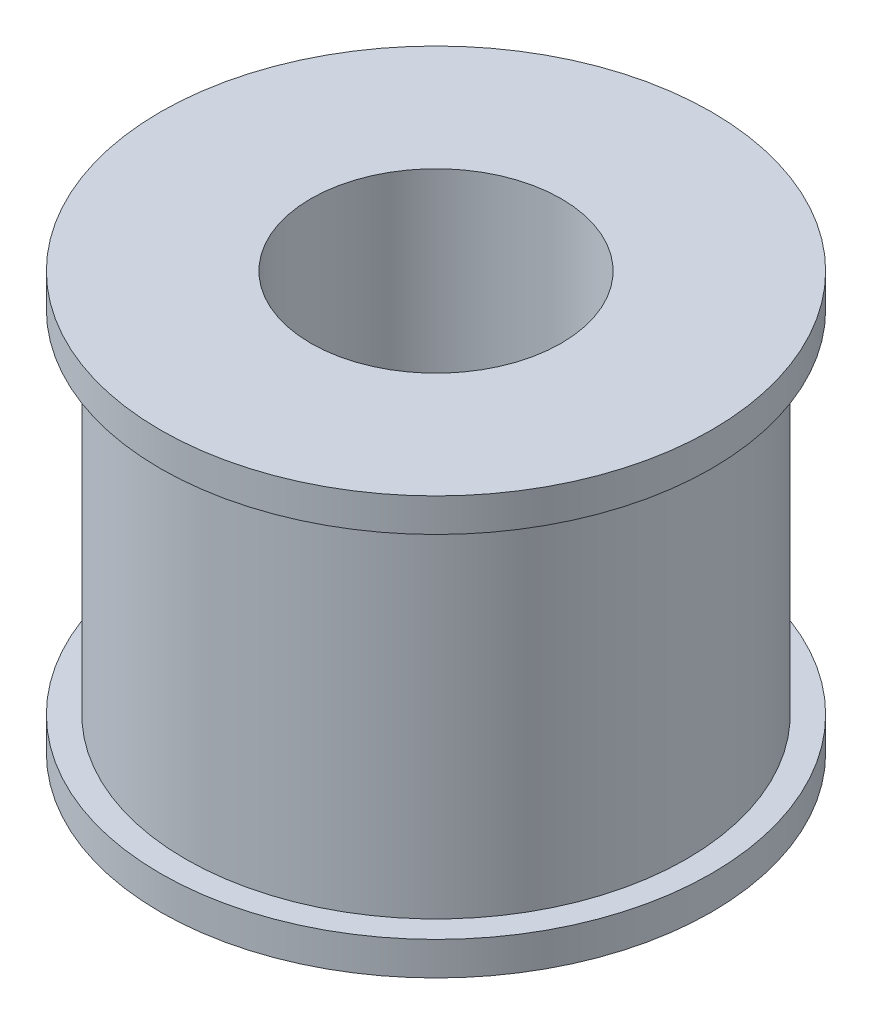
from build123d import *

# Parameters (mm, degrees)
CROQUIS1_R              = 15
CROQUIS1_R_2            = 3
SALIENTE_EXTRUIR1_DEPTH = 25
CROQUIS2_R              = 16.5
CROQUIS2_R_2            = 3
SALIENTE_EXTRUIR2_DEPTH = 2
CROQUIS3_R              = 16.5
CROQUIS3_R_2            = 3
SALIENTE_EXTRUIR3_DEPTH = 2
CORTAR_EXTRUIR1_REACH   = 18.5
CROQUIS4_R              = 1.625
CROQUIS5_R              = 7.5
CORTAR_EXTRUIR2_DEPTH   = 16


with BuildPart() as part:
    # Croquis1 → Saliente-Extruir1 (new body)
    with BuildSketch(Plane(origin=(0, 0, 0), x_dir=(1, 0, 0), z_dir=(0, 1, 0))):
        Circle(CROQUIS1_R)
        Circle(CROQUIS1_R_2, mode=Mode.SUBTRACT)
    extrude(amount=SALIENTE_EXTRUIR1_DEPTH)

    # Croquis2 → Saliente-Extruir2 (add)
    with BuildSketch(Plane.XZ):
        Circle(CROQUIS2_R)
        Circle(CROQUIS2_R_2, mode=Mode.SUBTRACT)
    extrude(amount=-SALIENTE_EXTRUIR2_DEPTH)

    # Croquis3 → Saliente-Extruir3 (add)
    with BuildSketch(Plane(origin=(0, 25, 0), x_dir=(1, 0, 0), z_dir=(0, 1, 0))):
        Circle(CROQUIS3_R)
        Circle(CROQUIS3_R_2, mode=Mode.SUBTRACT)
    extrude(amount=-SALIENTE_EXTRUIR3_DEPTH)

    # Croquis4 → Cortar-Extruir1 (cut, up to next)
    with BuildSketch(Plane.XY, mode=Mode.PRIVATE) as cortar_extruir1_sk1:
        with Locations((0, 5)):
            Circle(CROQUIS4_R)
    cortar_extruir1_tool1 = extrude(cortar_extruir1_sk1.sketch, amount=-CORTAR_EXTRUIR1_REACH, mode=Mode.PRIVATE) & part.part
    add(cortar_extruir1_tool1.solids().sort_by_distance((0, 5, 0))[0], mode=Mode.SUBTRACT)

    # Croquis5 → Cortar-Extruir2 (cut)
    with BuildSketch(Plane(origin=(0, 25, 0), x_dir=(1, 0, 0), z_dir=(0, 1, 0))):
        Circle(CROQUIS5_R)
    extrude(amount=-CORTAR_EXTRUIR2_DEPTH, mode=Mode.SUBTRACT)


solid = part.part
